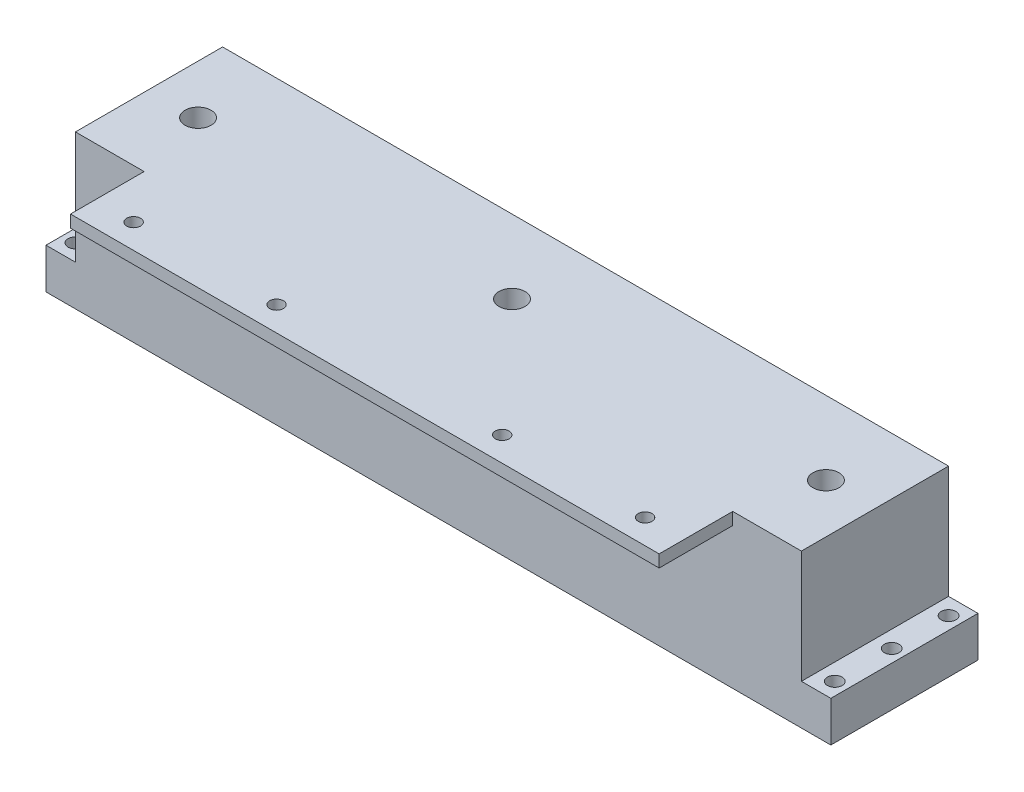
from build123d import *

# Parameters (mm, degrees)
SKETCH1_W           = 203.2
SKETCH1_H           = 38.1
BOSS_EXTRUDE1_DEPTH = 39.69258
SKETCH3_R           = 1.905
CUT_EXTRUDE1_DEPTH  = 40.69258
SKETCH4_R           = 3.3782
CUT_EXTRUDE3_DEPTH  = 40.69258
CUT_EXTRUDE5_DEPTH  = 6.35
SKETCH7_W           = 7.62
SKETCH7_H           = 38.1
CUT_EXTRUDE6_DEPTH  = 29.21
SKETCH8_W           = 152.4
SKETCH8_H           = 19.05
BOSS_EXTRUDE2_DEPTH = 3.175
SKETCH9_R           = 1.778
CUT_EXTRUDE7_DEPTH  = 3.175
SKETCH10_W          = 20.32
SKETCH10_H          = 12.7
CUT_EXTRUDE8_DEPTH  = 38.1
SCALE1_SCALE        = 1.02


with BuildPart() as part:
    # Sketch1 → Boss-Extrude1 (new body)
    with BuildSketch(Plane(origin=(0, 0, 0), x_dir=(1, 0, 0), z_dir=(0, 1, 0))):
        Rectangle(SKETCH1_W, SKETCH1_H)
    extrude(amount=BOSS_EXTRUDE1_DEPTH)

    # Sketch3 → Cut-Extrude1 (cut, through all)
    with BuildSketch(Plane.XZ):
        with Locations((-98.298, 14.732)):
            Circle(SKETCH3_R)
        with Locations((-98.298, 0)):
            Circle(SKETCH3_R)
        with Locations((-98.298, -14.732)):
            Circle(SKETCH3_R)
    cut_extrude1 = extrude(amount=-CUT_EXTRUDE1_DEPTH, mode=Mode.SUBTRACT)

    # Mirror1: Cut-Extrude1 across plane
    add(cut_extrude1.mirror(Plane(origin=(0, 0, 0), x_dir=(0, 0, 1), z_dir=(1, 0, 0))), mode=Mode.SUBTRACT)

    # Sketch4 → Cut-Extrude3 (cut, through all)
    with BuildSketch(Plane(origin=(0, 39.69258, 0), x_dir=(1, 0, 0), z_dir=(0, 1, 0))):
        Circle(SKETCH4_R)
        with Locations((81.28, 0)):
            Circle(SKETCH4_R)
        with Locations((-81.28, 0)):
            Circle(SKETCH4_R)
    extrude(amount=-CUT_EXTRUDE3_DEPTH, mode=Mode.SUBTRACT)

    # Sketch6 → Cut-Extrude5 (cut)
    with BuildSketch(Plane.XZ):
        Polygon((86.995, 3.299556788), (81.28, 6.599113577), (75.565, 3.299556788), (75.565, -3.299556788), (81.28, -6.599113577), (86.995, -3.299556788), align=None)
        Polygon((-86.995, -3.299556788), (-86.995, 3.299556788), (-81.28, 6.599113577), (-75.565, 3.299556788), (-75.565, -3.299556788), (-81.28, -6.599113577), align=None)
        Polygon((5.715, 3.299556788), (0, 6.599113577), (-5.715, 3.299556788), (-5.715, -3.299556788), (0, -6.599113577), (5.715, -3.299556788), align=None)
    extrude(amount=-CUT_EXTRUDE5_DEPTH, mode=Mode.SUBTRACT)

    # Sketch7 → Cut-Extrude6 (cut)
    with BuildSketch(Plane(origin=(0, 39.69258, 0), x_dir=(1, 0, 0), z_dir=(0, 1, 0))):
        with Locations((-97.79, 0)):
            Rectangle(SKETCH7_W, SKETCH7_H)
        with Locations((97.79, 0)):
            Rectangle(SKETCH7_W, SKETCH7_H)
    extrude(amount=-CUT_EXTRUDE6_DEPTH, mode=Mode.SUBTRACT)

    # Sketch8 → Boss-Extrude2 (add)
    with BuildSketch(Plane(origin=(0, 39.69258, 0), x_dir=(1, 0, 0), z_dir=(0, 1, 0))):
        with Locations((0, -28.575)):
            Rectangle(SKETCH8_W, SKETCH8_H)
    extrude(amount=-BOSS_EXTRUDE2_DEPTH)

    # Sketch9 → Cut-Extrude7 (cut)
    with BuildSketch(Plane.XZ.offset(-36.51758)):
        with Locations((29.21, 31.75)):
            Circle(SKETCH9_R)
        with Locations((66.21018, 31.75)):
            Circle(SKETCH9_R)
    cut_extrude7 = extrude(amount=-CUT_EXTRUDE7_DEPTH, mode=Mode.SUBTRACT)

    # Mirror2: Cut-Extrude7 across plane
    add(cut_extrude7.mirror(Plane(origin=(0, 0, 0), x_dir=(0, 0, 1), z_dir=(1, 0, 0))), mode=Mode.SUBTRACT)

    # Sketch10 → Cut-Extrude8 (cut)
    with BuildSketch(Plane.XY.offset(19.05)):
        with Locations((48.26, 30.16758)):
            Rectangle(SKETCH10_W, SKETCH10_H)
    cut_extrude8 = extrude(amount=-CUT_EXTRUDE8_DEPTH, mode=Mode.SUBTRACT)

    # Mirror3: Cut-Extrude8 across plane
    add(cut_extrude8.mirror(Plane(origin=(0, 0, 0), x_dir=(0, 0, 1), z_dir=(1, 0, 0))), mode=Mode.SUBTRACT)


with BuildPart() as part_1:
    # Scale1: scaled about (0, 19.51392143, 0.949094237)
    add(part.part.scale(SCALE1_SCALE).moved(Location((0, -0.390278429, -0.018981885))))


solid = part_1.part
